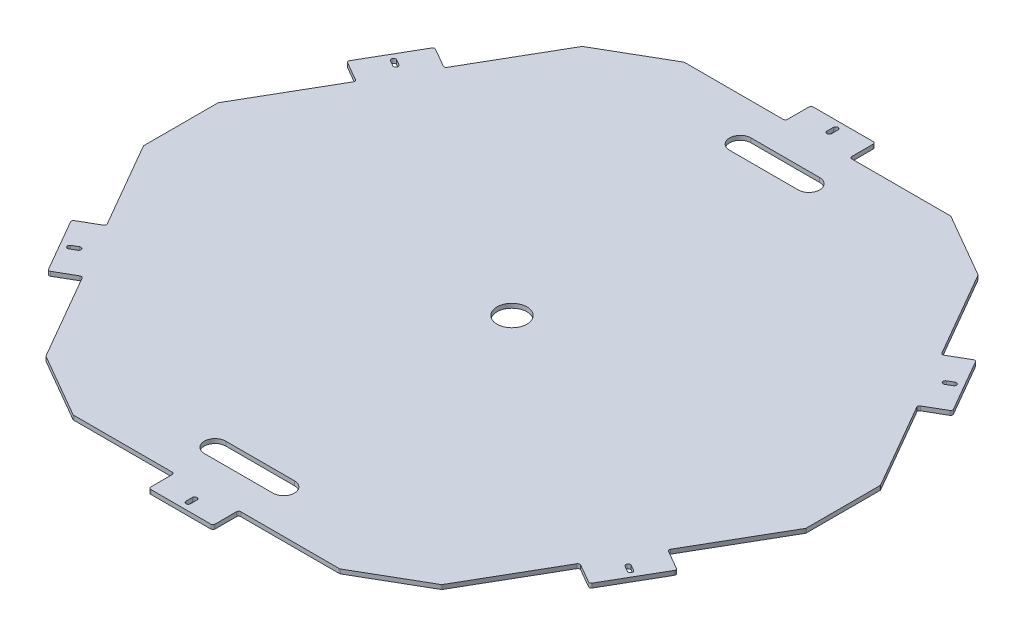
from build123d import *

# Parameters (mm, degrees)
BOSS_EXTRUDE1_DEPTH = 6.35
SKETCH2_R           = 22.225
CUT_EXTRUDE1_DEPTH  = 6.35
FILLET2_R           = 3.175


with BuildPart() as part:
    # Sketch1 → Boss-Extrude1 (new body)
    with BuildSketch(Plane(origin=(0, 0, 0), x_dir=(1, 0, 0), z_dir=(0, 1, 0))):
        Polygon((359.098373018, -359.098373018), (490.5375, -131.439126982), (490.5375, 131.439126982), (359.098373018, 359.098373018), (131.439126982, 490.5375), (-131.439126982, 490.5375), (-359.098373018, 359.098373018), (-490.5375, 131.439126982), (-490.5375, -131.439126982), (-359.098373018, -359.098373018), (-131.439126982, -490.5375), (131.439126982, -490.5375), align=None)
    extrude(amount=BOSS_EXTRUDE1_DEPTH)

    # Sketch2 → Cut-Extrude1 (cut)
    with BuildSketch(Plane(origin=(0, 6.35, 0), x_dir=(1, 0, 0), z_dir=(0, 1, 0))):
        Circle(SKETCH2_R)
        Polygon((-131.439126982, 490.5375), (-197.430262751, 452.4375), (-47.625, 452.4375), (-47.625, 490.5375), align=None)
        Polygon((131.439126982, 490.5375), (47.625, 490.5375), (47.625, 452.4375), (197.430262751, 452.4375), align=None)
        with BuildLine():
            Line((3.3734375, 479.425), (3.3734375, 469.9))
            ThreePointArc((3.3734375, 469.9), (0, 466.5265625), (-3.3734375, 469.9))
            Line((-3.3734375, 469.9), (-3.3734375, 479.425))
            ThreePointArc((-3.3734375, 479.425), (0, 482.7984375), (3.3734375, 479.425))
        make_face()
        with BuildLine():
            Line((-50.8, 404.8125), (50.8, 404.8125))
            ThreePointArc((50.8, 404.8125), (66.675, 388.9375), (50.8, 373.0625))
            Line((50.8, 373.0625), (-50.8, 373.0625))
            ThreePointArc((-50.8, 373.0625), (-66.675, 388.9375), (-50.8, 404.8125))
        make_face()
        Polygon((401.005436509, 286.513209855), (359.098373018, 359.098373018), (293.107237249, 397.198373018), (368.009868625, 267.463209855), align=None)
        Polygon((490.5375, 55.239126982), (490.5375, 131.439126982), (448.630436509, 204.024290145), (415.634868625, 184.974290145), align=None)
        Polygon((448.630436509, -204.024290145), (490.5375, -131.439126982), (490.5375, -55.239126982), (415.634868625, -184.974290145), align=None)
        Polygon((293.107237249, -397.198373018), (359.098373018, -359.098373018), (401.005436509, -286.513209855), (368.009868625, -267.463209855), align=None)
        Polygon((47.625, -490.5375), (131.439126982, -490.5375), (197.430262751, -452.4375), (47.625, -452.4375), align=None)
        Polygon((-197.430262751, -452.4375), (-131.439126982, -490.5375), (-47.625, -490.5375), (-47.625, -452.4375), align=None)
        Polygon((-401.005436509, -286.513209855), (-359.098373018, -359.098373018), (-293.107237249, -397.198373018), (-368.009868625, -267.463209855), align=None)
        Polygon((-490.5375, -55.239126982), (-490.5375, -131.439126982), (-448.630436509, -204.024290145), (-415.634868625, -184.974290145), align=None)
        Polygon((-448.630436509, 204.024290145), (-490.5375, 131.439126982), (-490.5375, 55.239126982), (-415.634868625, 184.974290145), align=None)
        Polygon((-293.107237249, 397.198373018), (-359.098373018, 359.098373018), (-401.005436509, 286.513209855), (-368.009868625, 267.463209855), align=None)
        with BuildLine():
            Line((-413.507510459, 242.633982573), (-405.258618488, 237.871482573))
            ThreePointArc((-405.258618488, 237.871482573), (-404.023854665, 233.26328125), (-408.632055988, 232.028517427))
            Line((-408.632055988, 232.028517427), (-416.880947959, 236.791017427))
            ThreePointArc((-416.880947959, 236.791017427), (-418.115711782, 241.39921875), (-413.507510459, 242.633982573))
        make_face()
        with BuildLine():
            Line((416.880947959, 236.791017427), (408.632055988, 232.028517427))
            ThreePointArc((408.632055988, 232.028517427), (404.023854665, 233.26328125), (405.258618488, 237.871482573))
            Line((405.258618488, 237.871482573), (413.507510459, 242.633982573))
            ThreePointArc((413.507510459, 242.633982573), (418.115711782, 241.39921875), (416.880947959, 236.791017427))
        make_face()
        with BuildLine():
            Line((416.880947959, -236.791017427), (408.632055988, -232.028517427))
            ThreePointArc((408.632055988, -232.028517427), (404.023854665, -233.26328125), (405.258618488, -237.871482573))
            Line((405.258618488, -237.871482573), (413.507510459, -242.633982573))
            ThreePointArc((413.507510459, -242.633982573), (418.115711782, -241.39921875), (416.880947959, -236.791017427))
        make_face()
        with BuildLine():
            Line((-50.8, -404.8125), (50.8, -404.8125))
            ThreePointArc((50.8, -404.8125), (66.675, -388.9375), (50.8, -373.0625))
            Line((50.8, -373.0625), (-50.8, -373.0625))
            ThreePointArc((-50.8, -373.0625), (-66.675, -388.9375), (-50.8, -404.8125))
        make_face()
        with BuildLine():
            Line((3.3734375, -479.425), (3.3734375, -469.9))
            ThreePointArc((3.3734375, -469.9), (0, -466.5265625), (-3.3734375, -469.9))
            Line((-3.3734375, -469.9), (-3.3734375, -479.425))
            ThreePointArc((-3.3734375, -479.425), (0, -482.7984375), (3.3734375, -479.425))
        make_face()
        with BuildLine():
            Line((-413.507510459, -242.633982573), (-405.258618488, -237.871482573))
            ThreePointArc((-405.258618488, -237.871482573), (-404.023854665, -233.26328125), (-408.632055988, -232.028517427))
            Line((-408.632055988, -232.028517427), (-416.880947959, -236.791017427))
            ThreePointArc((-416.880947959, -236.791017427), (-418.115711782, -241.39921875), (-413.507510459, -242.633982573))
        make_face()
    extrude(amount=-CUT_EXTRUDE1_DEPTH, mode=Mode.SUBTRACT)

    # Fillet2
    fillet2_edges = [part.edges().sort_by_distance(p)[0] for p in [
        (-47.625, 3.175, 490.5375),
        (-197.430262751, 3.175, 452.4375),
        (-47.625, 3.175, 452.4375),
        (-293.107237249, 3.175, 397.198373018),
        (-401.005436509, 3.175, 286.513209855),
        (-368.009868625, 3.175, 267.463209855),
        (-448.630436509, 3.175, 204.024290145),
        (-490.5375, 3.175, 55.239126982),
        (-415.634868625, 3.175, 184.974290145),
        (-490.5375, 3.175, -55.239126982),
        (-448.630436509, 3.175, -204.024290145),
        (-415.634868625, 3.175, -184.974290145),
        (-401.005436509, 3.175, -286.513209855),
        (-293.107237249, 3.175, -397.198373018),
        (-368.009868625, 3.175, -267.463209855),
        (197.430262751, 3.175, 452.4375),
        (47.625, 3.175, 490.5375),
        (47.625, 3.175, 452.4375),
        (401.005436509, 3.175, 286.513209855),
        (293.107237249, 3.175, 397.198373018),
        (368.009868625, 3.175, 267.463209855),
        (490.5375, 3.175, 55.239126982),
        (448.630436509, 3.175, 204.024290145),
        (415.634868625, 3.175, 184.974290145),
        (448.630436509, 3.175, -204.024290145),
        (490.5375, 3.175, -55.239126982),
        (415.634868625, 3.175, -184.974290145),
        (293.107237249, 3.175, -397.198373018),
        (401.005436509, 3.175, -286.513209855),
        (368.009868625, 3.175, -267.463209855),
        (197.430262751, 3.175, -452.4375),
        (47.625, 3.175, -452.4375),
        (47.625, 3.175, -490.5375),
        (-47.625, 3.175, -490.5375),
        (-47.625, 3.175, -452.4375),
        (-197.430262751, 3.175, -452.4375),
    ]]
    fillet(fillet2_edges, radius=FILLET2_R)


solid = part.part
